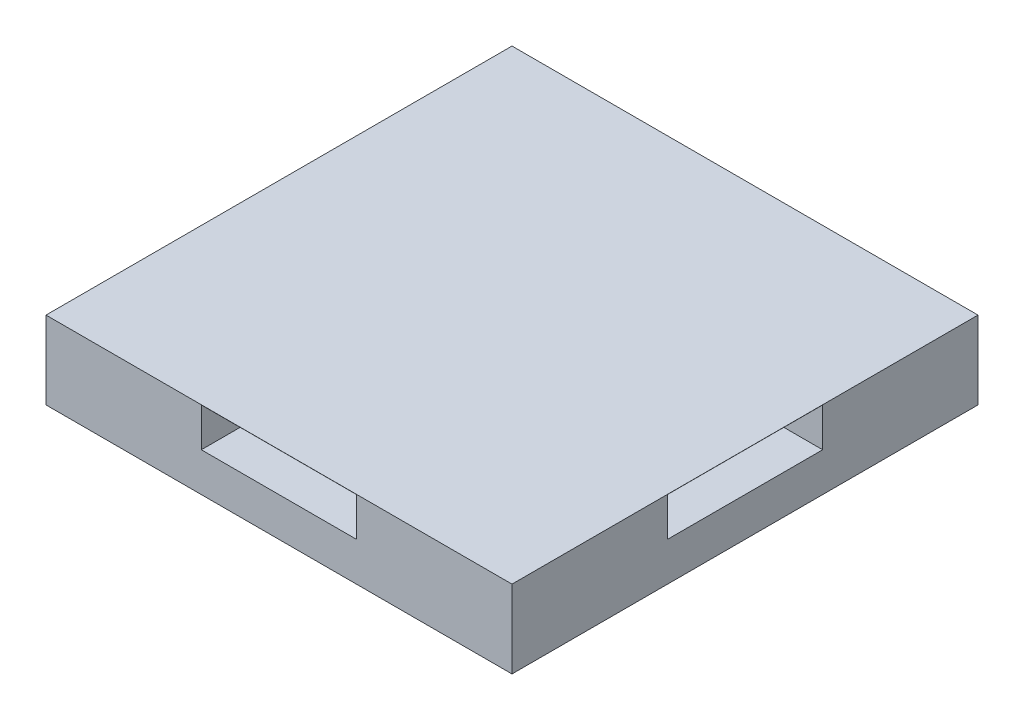
from build123d import *

# Parameters (mm, degrees)
SKETCH1_W           = 76.2
SKETCH1_H           = 76.2
BOSS_EXTRUDE1_DEPTH = 12.7
SKETCH2_W           = 25.4
SKETCH2_H           = 10.414
SKETCH2_W_2         = 10.414
SKETCH2_H_2         = 25.4
CUT_EXTRUDE1_DEPTH  = 6.35
SKETCH3_W           = 76.2
SKETCH3_H           = 76.2
BOSS_EXTRUDE2_DEPTH = 0.0254


with BuildPart() as part:
    # Sketch1 → Boss-Extrude1 (new body)
    with BuildSketch(Plane(origin=(0, 0, 0), x_dir=(1, 0, 0), z_dir=(0, 1, 0))):
        with Locations((38.1, 38.1)):
            Rectangle(SKETCH1_W, SKETCH1_H)
    extrude(amount=BOSS_EXTRUDE1_DEPTH)

    # Sketch2 → Cut-Extrude1 (cut)
    with BuildSketch(Plane(origin=(0, 12.7, 0), x_dir=(1, 0, 0), z_dir=(0, 1, 0))):
        with Locations((38.1, 70.993)):
            Rectangle(SKETCH2_W, SKETCH2_H)
        with Locations((5.207, 38.1)):
            Rectangle(SKETCH2_W_2, SKETCH2_H_2)
        with Locations((38.1, 5.207)):
            Rectangle(SKETCH2_W, SKETCH2_H)
        with Locations((70.993, 38.1)):
            Rectangle(SKETCH2_W_2, SKETCH2_H_2)
    extrude(amount=-CUT_EXTRUDE1_DEPTH, mode=Mode.SUBTRACT)

    # Sketch3 → Boss-Extrude2 (add)
    with BuildSketch(Plane(origin=(0, 12.7, 0), x_dir=(1, 0, 0), z_dir=(0, 1, 0))):
        with Locations((38.1, 38.1)):
            Rectangle(SKETCH3_W, SKETCH3_H)
    extrude(amount=BOSS_EXTRUDE2_DEPTH)


solid = part.part
